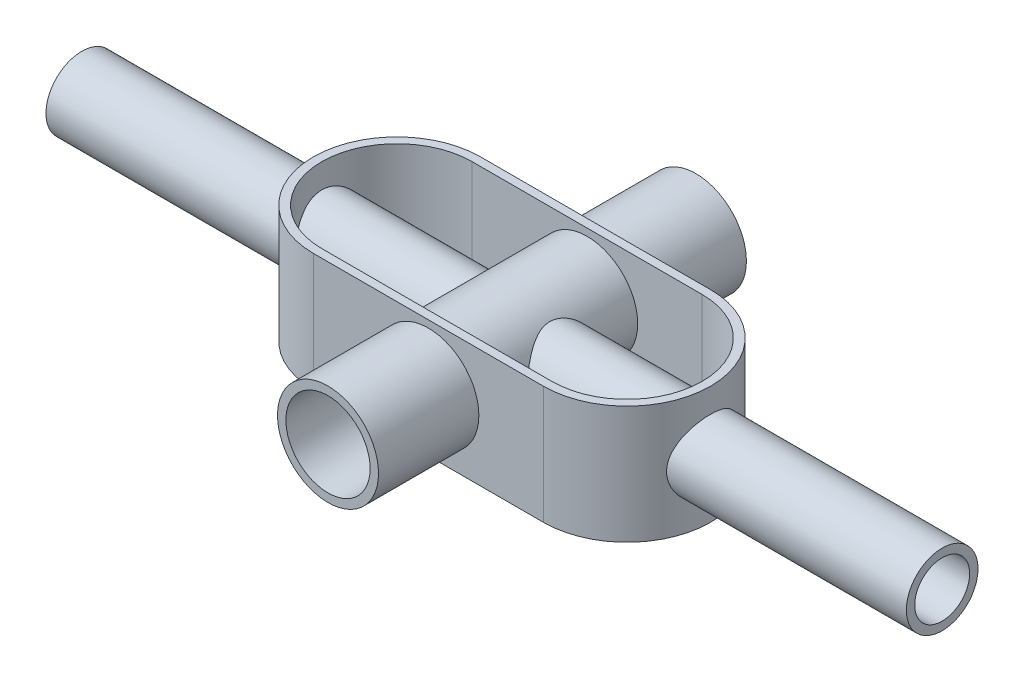
from build123d import *

# Parameters (mm, degrees)
BOSS_EXTRUDE1_DEPTH = 35.814
SHELL1_T            = -2.54
SKETCH2_R           = 10.884269179
SKETCH2_R_2         = 8.344269179
EXTRUDE_THIN1_DEPTH = 130.683
SKETCH3_R           = 15.338870546
SKETCH3_R_2         = 12.798870546
EXTRUDE_THIN2_DEPTH = 55.88


with BuildPart() as part:
    # Sketch1 → Boss-Extrude1 (new body)
    with BuildSketch(Plane(origin=(0, 0, 0), x_dir=(1, 0, 0), z_dir=(0, 1, 0))):
        with BuildLine():
            Line((-34.942128478, 25.392607038), (34.942128478, 25.392607038))
            ThreePointArc((34.942128478, 25.392607038), (60.334735516, 0), (34.942128478, -25.392607038))
            Line((34.942128478, -25.392607038), (-34.942128478, -25.392607038))
            ThreePointArc((-34.942128478, -25.392607038), (-60.334735516, 0), (-34.942128478, 25.392607038))
        make_face()
    extrude(amount=BOSS_EXTRUDE1_DEPTH)

    # Shell1
    shell1_openings = [part.faces().sort_by_distance(p)[0] for p in [
        (0, 35.814, 0),
    ]]
    offset(amount=SHELL1_T, openings=shell1_openings, kind=Kind.INTERSECTION)


with BuildPart() as body_2:
    # Sketch2 → Extrude-Thin1 (new body, symmetric)
    with BuildSketch(Plane(origin=(0, 0, 0), x_dir=(0, 0, -1), z_dir=(1, 0, 0))):
        with Locations((0, 17.525247937)):
            Circle(SKETCH2_R)
        with Locations((0, 17.525247937)):
            Circle(SKETCH2_R_2, mode=Mode.SUBTRACT)
    extrude(amount=EXTRUDE_THIN1_DEPTH, both=True)


with BuildPart() as body_3:
    # Sketch3 → Extrude-Thin2 (new body, symmetric)
    with BuildSketch(Plane.XY):
        with Locations((0, 18.299937242)):
            Circle(SKETCH3_R)
        with Locations((0, 18.299937242)):
            Circle(SKETCH3_R_2, mode=Mode.SUBTRACT)
    extrude(amount=EXTRUDE_THIN2_DEPTH, both=True)


solid = Compound([part.part, body_2.part, body_3.part])
